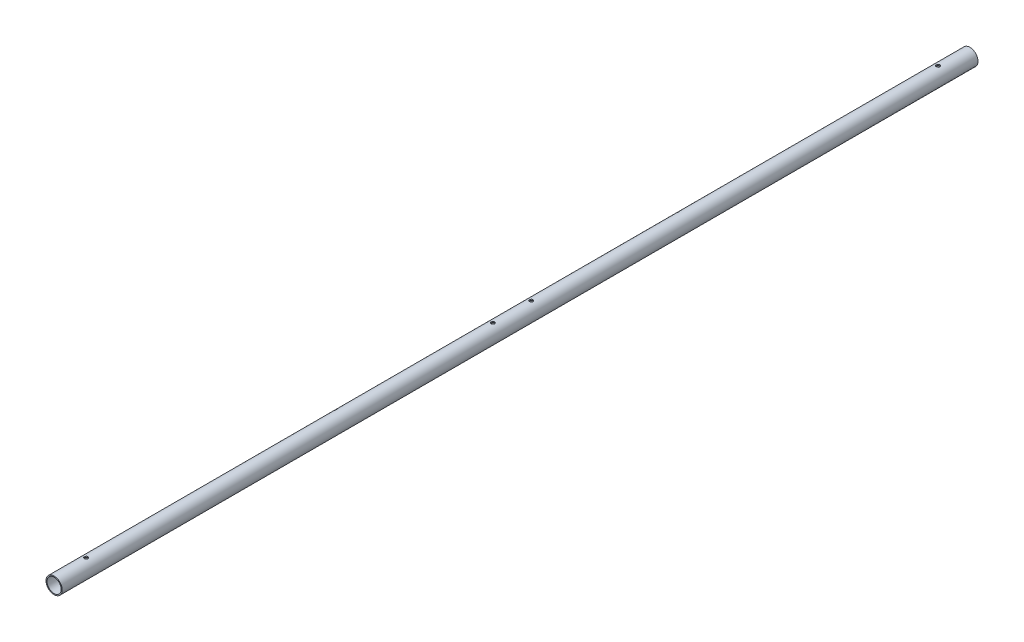
from build123d import *

# Parameters (mm, degrees)
SKETCH1_R                                  = 12.7
SKETCH1_R_2                                = 11.1125
BOSS_EXTRUDE1_DEPTH                        = 716.7546056
M5_CLEARANCE_HOLE1_D                       = 5.5
SKETCH7_W                                  = 2.75
SKETCH7_H                                  = 12.7
MIRROR1_AT_THE_SECOND_PLANE_COPY_1_SKETC_W = 2.75
MIRROR1_AT_THE_SECOND_PLANE_COPY_1_SKETC_H = 12.7
CUT_EXTRUDE1_START                         = -12.7
SKETCH8_R                                  = 2.5
CUT_EXTRUDE1_DEPTH                         = 25.4


with BuildPart() as part:
    # Sketch1 → Boss-Extrude1 (new body, symmetric)
    with BuildSketch(Plane.XY):
        Circle(SKETCH1_R)
        Circle(SKETCH1_R_2, mode=Mode.SUBTRACT)
    extrude(amount=BOSS_EXTRUDE1_DEPTH, both=True)

    # M5 Clearance Hole1 (through all)
    with Locations(Plane(origin=(0, 12.7, 0), x_dir=(1, 0, 0), z_dir=(0, 1, 0))):
        with Locations((0, 30), (0, -30)):
            Hole(M5_CLEARANCE_HOLE1_D / 2)

    # Sketch7 → M5 Clearance Hole2 (revolve, cut)
    with BuildSketch(Plane(origin=(0, 0, 666.7546056), x_dir=(0, 0, -1), z_dir=(1, 0, 0))):
        with Locations((1.375, 6.35)):
            Rectangle(SKETCH7_W, SKETCH7_H)
    m5_clearance_hole2 = revolve(axis=Axis((0, -6.35, 666.7546056), (0, 1, 0)), mode=Mode.SUBTRACT)

    # Mirror1: M5 Clearance Hole2 across plane
    add(m5_clearance_hole2.mirror(Plane.ZX), mode=Mode.SUBTRACT)

    # Mirror1 at the second plane: M5 Clearance Hole2 across plane
    add(m5_clearance_hole2.mirror(Plane.XY), mode=Mode.SUBTRACT)

    # Mirror1 at the second plane copy 1 sketc → Mirror1 at the second plane copy 1 (revolve, cut)
    with BuildSketch(Plane(origin=(0, 0, -666.7546056), x_dir=(0, 0, 1), z_dir=(1, 0, 0))):
        with Locations((1.375, 6.35)):
            Rectangle(MIRROR1_AT_THE_SECOND_PLANE_COPY_1_SKETC_W, MIRROR1_AT_THE_SECOND_PLANE_COPY_1_SKETC_H)
    revolve(axis=Axis((0, 6.35, -666.7546056), (0, -1, 0)), mode=Mode.SUBTRACT)

    # Sketch8 → Cut-Extrude1 (cut)
    with BuildSketch(Plane(origin=(0, 0, 0), x_dir=(-0.834407926, -0.55114736, 0), z_dir=(0.55114736, -0.834407926, 0)).offset(CUT_EXTRUDE1_START)):
        with Locations((1.717033262, 267.917598195)):
            Circle(SKETCH8_R)
    cut_extrude1 = extrude(amount=CUT_EXTRUDE1_DEPTH, mode=Mode.SUBTRACT)

    # Mirror2: Cut-Extrude1 across plane
    add(cut_extrude1.mirror(Plane.XY), mode=Mode.SUBTRACT)


solid = part.part
